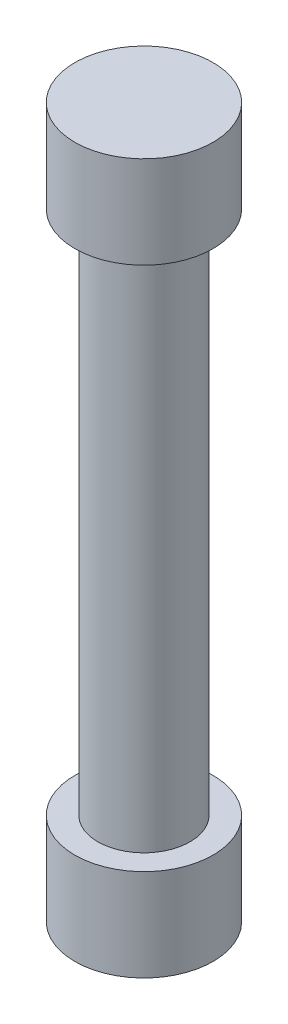
from build123d import *

# Parameters (mm, degrees)
SKETCH1_R           = 1.5
BOSS_EXTRUDE1_DEPTH = 17.1
SKETCH2_R           = 2.25
BOSS_EXTRUDE2_DEPTH = 3
BOSS_EXTRUDE3_START = -17.1
SKETCH2_2_R         = 2.25
BOSS_EXTRUDE3_DEPTH = 3


with BuildPart() as part:
    # Sketch1 → Boss-Extrude1 (new body)
    with BuildSketch(Plane(origin=(0, 0, 0), x_dir=(1, 0, 0), z_dir=(0, 1, 0))):
        Circle(SKETCH1_R)
    extrude(amount=BOSS_EXTRUDE1_DEPTH)

    # Sketch2 → Boss-Extrude2 (add)
    with BuildSketch(Plane(origin=(0, 17.1, 0), x_dir=(1, 0, 0), z_dir=(0, 1, 0))):
        Circle(SKETCH2_R)
    extrude(amount=BOSS_EXTRUDE2_DEPTH)

    # Sketch2_2 → Boss-Extrude3 (add)
    with BuildSketch(Plane(origin=(0, 17.1, 0), x_dir=(1, 0, 0), z_dir=(0, 1, 0)).offset(BOSS_EXTRUDE3_START)):
        Circle(SKETCH2_2_R)
    extrude(amount=-BOSS_EXTRUDE3_DEPTH)


solid = part.part
